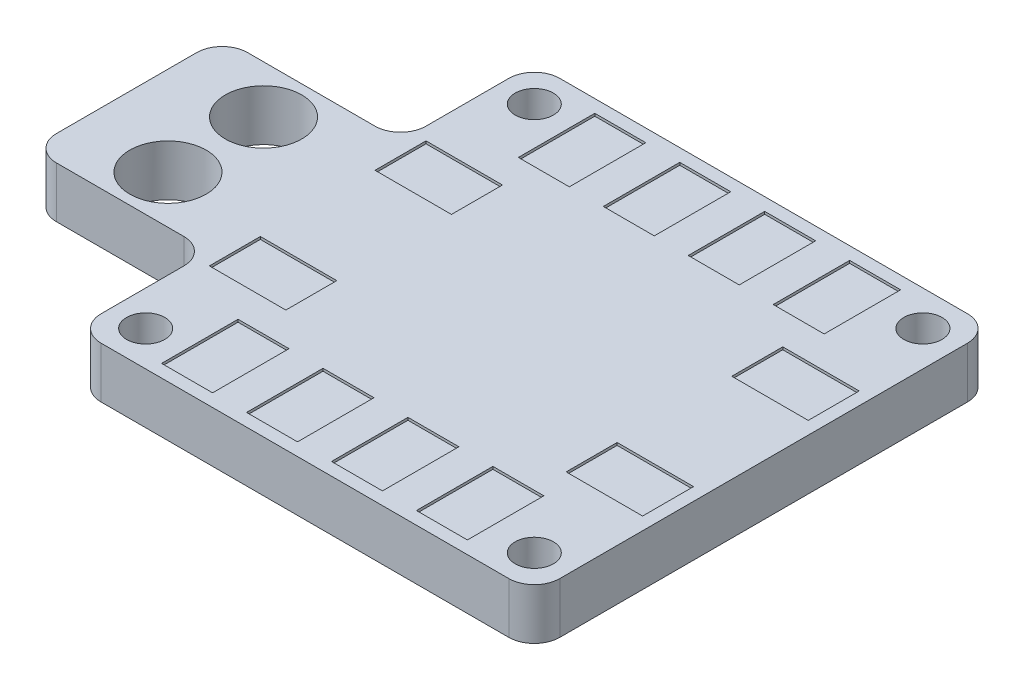
from build123d import *

# Parameters (mm, degrees)
SKETCH1_W               = 14
SKETCH1_H               = 15
BOSS_EXTRUDE1_DEPTH     = 4
SKETCH2_R               = 3
SKETCH2_R_2             = 1.5
CUT_EXTRUDE1_DEPTH      = 1
CUT_EXTRUDE1_DEPTH_BACK = 5
FILLET1_R               = 2
CUT_EXTRUDE2_START      = -0.2
SKETCH3_W               = 4
SKETCH3_H               = 6
CUT_EXTRUDE2_DEPTH      = 1.2
LPATTERN1_COUNT         = 4
LPATTERN1_PITCH         = 6.666666667
MIRROR1_START           = -0.2
MIRROR1_COPY_1_SKETCH_W = 4
MIRROR1_COPY_1_SKETCH_H = 6
MIRROR1_COPY_1_DEPTH    = 1.2
MIRROR1_COPY_2_SKETCH_W = 4
MIRROR1_COPY_2_SKETCH_H = 6
MIRROR1_COPY_2_DEPTH    = 1.2
MIRROR1_COPY_3_SKETCH_W = 4
MIRROR1_COPY_3_SKETCH_H = 6
MIRROR1_COPY_3_DEPTH    = 1.2
SKETCH4_W               = 6
SKETCH4_H               = 4
CUT_EXTRUDE3_DEPTH      = 1
CUT_EXTRUDE3_DEPTH_BACK = 0.2


with BuildPart() as part:
    # Sketch1 → Boss-Extrude1 (new body)
    with BuildSketch(Plane(origin=(0, 0, 0), x_dir=(1, 0, 0), z_dir=(0, 1, 0))):
        Polygon((-11, 18), (-11, 7.5), (-11, -7.5), (-11, -18), (25, -18), (25, 18), align=None)
        with Locations((-18, 0)):
            Rectangle(SKETCH1_W, SKETCH1_H)
    extrude(amount=BOSS_EXTRUDE1_DEPTH)

    # Sketch2 → Cut-Extrude1 (cut, two sides)
    with BuildSketch(Plane(origin=(0, 4, 0), x_dir=(1, 0, 0), z_dir=(0, 1, 0))) as cut_extrude1_sk:
        with Locations((-18, 3.75)):
            Circle(SKETCH2_R)
        with Locations((-8.25, 15.25)):
            Circle(SKETCH2_R_2)
        with Locations((22.25, 15.25)):
            Circle(SKETCH2_R_2)
        with Locations((-18, -3.75)):
            Circle(SKETCH2_R)
        with Locations((22.25, -15.25)):
            Circle(SKETCH2_R_2)
        with Locations((-8.25, -15.25)):
            Circle(SKETCH2_R_2)
    extrude(amount=CUT_EXTRUDE1_DEPTH, mode=Mode.SUBTRACT)
    extrude(cut_extrude1_sk.sketch, amount=-CUT_EXTRUDE1_DEPTH_BACK, mode=Mode.SUBTRACT)

    # Fillet1
    fillet1_edges = [part.edges().sort_by_distance(p)[0] for p in [
        (-11, 2, -18),
        (25, 2, -18),
        (25, 2, 18),
        (-11, 2, 18),
        (-11, 2, 7.5),
        (-25, 2, 7.5),
        (-25, 2, -7.5),
        (-11, 2, -7.5),
    ]]
    fillet(fillet1_edges, radius=FILLET1_R)

    # Sketch3 → Cut-Extrude2 (cut)
    with BuildSketch(Plane(origin=(0, 4, 0), x_dir=(1, 0, 0), z_dir=(0, 1, 0)).offset(CUT_EXTRUDE2_START)):
        with Locations((-3.25, 14)):
            Rectangle(SKETCH3_W, SKETCH3_H)
    cut_extrude2 = extrude(amount=CUT_EXTRUDE2_DEPTH, mode=Mode.SUBTRACT)

    # LPattern1: Cut-Extrude2 ×4
    with Locations(*[(i * LPATTERN1_PITCH, 0, 0) for i in range(1, LPATTERN1_COUNT)]):
        add(cut_extrude2, mode=Mode.SUBTRACT)

    # Mirror1: Cut-Extrude2 across plane
    add(cut_extrude2.mirror(Plane.XY), mode=Mode.SUBTRACT)

    # Mirror1 copy 1 sketch → Mirror1 copy 1 (cut)
    with BuildSketch(Plane(origin=(6.666666667, 4, 0), x_dir=(1, 0, 0), z_dir=(0, 1, 0)).offset(MIRROR1_START)):
        with Locations((-3.25, -14)):
            Rectangle(MIRROR1_COPY_1_SKETCH_W, MIRROR1_COPY_1_SKETCH_H)
    extrude(amount=MIRROR1_COPY_1_DEPTH, mode=Mode.SUBTRACT)

    # Mirror1 copy 2 sketch → Mirror1 copy 2 (cut)
    with BuildSketch(Plane(origin=(13.333333333, 4, 0), x_dir=(1, 0, 0), z_dir=(0, 1, 0)).offset(MIRROR1_START)):
        with Locations((-3.25, -14)):
            Rectangle(MIRROR1_COPY_2_SKETCH_W, MIRROR1_COPY_2_SKETCH_H)
    extrude(amount=MIRROR1_COPY_2_DEPTH, mode=Mode.SUBTRACT)

    # Mirror1 copy 3 sketch → Mirror1 copy 3 (cut)
    with BuildSketch(Plane(origin=(20, 4, 0), x_dir=(1, 0, 0), z_dir=(0, 1, 0)).offset(MIRROR1_START)):
        with Locations((-3.25, -14)):
            Rectangle(MIRROR1_COPY_3_SKETCH_W, MIRROR1_COPY_3_SKETCH_H)
    extrude(amount=MIRROR1_COPY_3_DEPTH, mode=Mode.SUBTRACT)

    # Sketch4 → Cut-Extrude3 (cut, two sides)
    with BuildSketch(Plane(origin=(0, 4, 0), x_dir=(1, 0, 0), z_dir=(0, 1, 0))) as cut_extrude3_sk:
        with Locations((21, 6.5)):
            Rectangle(SKETCH4_W, SKETCH4_H)
        with Locations((-7, 6.5)):
            Rectangle(SKETCH4_W, SKETCH4_H)
        with Locations((-7, -6.5)):
            Rectangle(SKETCH4_W, SKETCH4_H)
        with Locations((21, -6.5)):
            Rectangle(SKETCH4_W, SKETCH4_H)
    extrude(amount=CUT_EXTRUDE3_DEPTH, mode=Mode.SUBTRACT)
    extrude(cut_extrude3_sk.sketch, amount=-CUT_EXTRUDE3_DEPTH_BACK, mode=Mode.SUBTRACT)


solid = part.part
